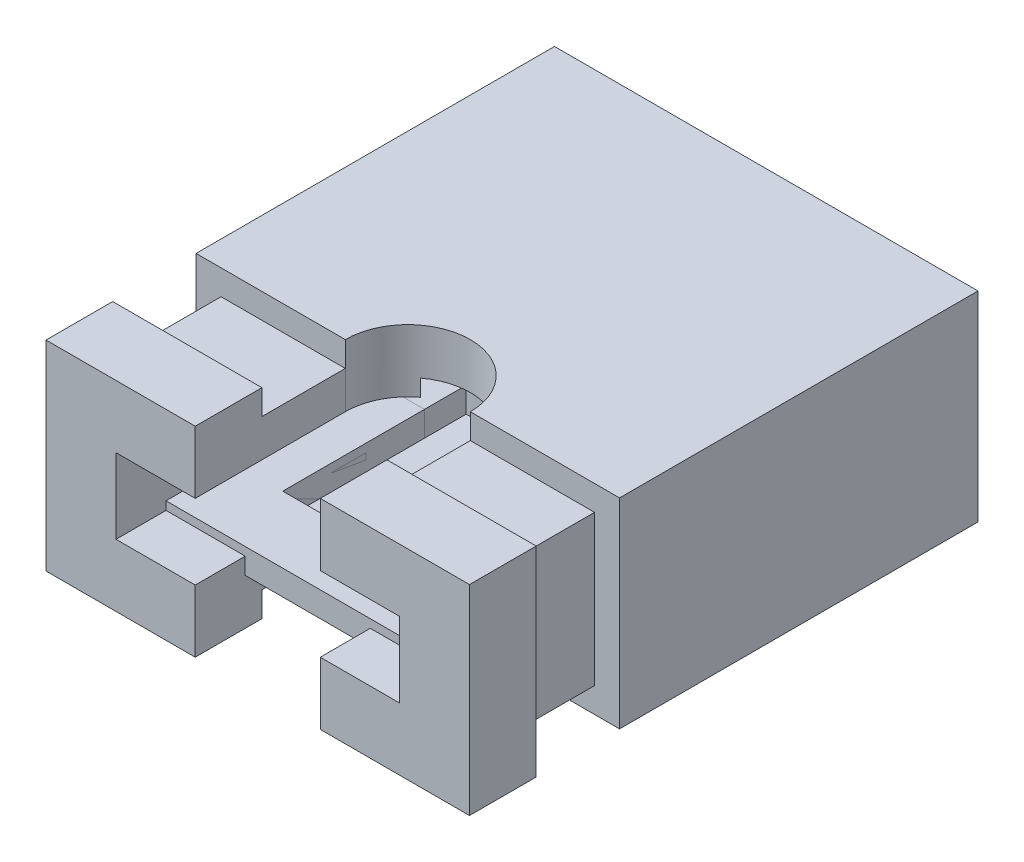
from build123d import *

# Parameters (mm, degrees)
SKETCH1_W           = 5.08
SKETCH1_H           = 2.4
SKETCH1_W_2         = 3.799999998
SKETCH1_H_2         = 1.299999999
BOSS_EXTRUDE1_DEPTH = 4.3
SKETCH3_R           = 0.75
CUT_EXTRUDE2_DEPTH  = 3.4
BOSS_EXTRUDE2_DEPTH = 1
BOSS_EXTRUDE3_DEPTH = 0.8
BOSS_EXTRUDE4_DEPTH = 2.4
CUT_EXTRUDE4_DEPTH  = 2.849999999
BOSS_EXTRUDE5_DEPTH = 3
BOSS_EXTRUDE8_DEPTH = 2.5
SKETCH14_W          = 2.199999998
SKETCH14_H          = 2.2
CUT_EXTRUDE5_DEPTH  = 0.3


with BuildPart() as part:
    # Sketch1 → Boss-Extrude1 (new body)
    with BuildSketch(Plane.XY):
        Rectangle(SKETCH1_W, SKETCH1_H)
        Rectangle(SKETCH1_W_2, SKETCH1_H_2, mode=Mode.SUBTRACT)
    extrude(amount=BOSS_EXTRUDE1_DEPTH)

    # Sketch3 → Cut-Extrude2 (cut, through all)
    with BuildSketch(Plane(origin=(0, 1.2, 0), x_dir=(1, 0, 0), z_dir=(0, 1, 0))):
        with Locations((0, -4.3)):
            Circle(SKETCH3_R)
    extrude(amount=-CUT_EXTRUDE2_DEPTH, mode=Mode.SUBTRACT)

    # Sketch6 → Boss-Extrude2 (add)
    with BuildSketch(Plane.XY.offset(4.3)):
        Polygon((-0.75, 0.9), (-0.75, 0.649999999), (-1.899999999, 0.649999999), (-1.899999999, -0.65), (-0.75, -0.65), (-0.75, -0.9), (-2.24, -0.9), (-2.24, 0.9), align=None)
        Polygon((2.24, 0.9), (2.24, -0.9), (0.75, -0.9), (0.75, -0.65), (1.899999999, -0.65), (1.899999999, 0.649999999), (0.75, 0.649999999), (0.75, 0.9), align=None)
    extrude(amount=BOSS_EXTRUDE2_DEPTH)

    # Sketch7 → Boss-Extrude3 (add)
    with BuildSketch(Plane.XY.offset(5.3)):
        Polygon((-0.75, 1.2), (-0.75, 0.9), (-0.75, 0.649999999), (-1.899999999, 0.649999999), (-1.899999999, -0.65), (-0.75, -0.65), (-0.75, -0.9), (-0.75, -1.2), (-2.54, -1.2), (-2.54, 1.2), align=None)
        Polygon((0.75, -0.9), (0.75, -1.2), (2.54, -1.2), (2.54, 1.2), (0.75, 1.2), (0.75, 0.9), (0.75, 0.649999999), (1.899999999, 0.649999999), (1.899999999, -0.65), (0.75, -0.65), align=None)
    extrude(amount=BOSS_EXTRUDE3_DEPTH)

    # Sketch9 → Boss-Extrude4 (add)
    with BuildSketch(Plane.XY.offset(6.1)):
        Polygon((0.75, 0.649999999), (1.899999999, 0.649999999), (1.899999999, -0.65), (0.75, -0.65), (-0.75, -0.65), (-1.899999999, -0.65), (-1.899999999, 0.649999999), (-0.75, 0.649999999), align=None)
        Polygon((-0.75, -0.45), (-1.699999999, -0.45), (-1.699999999, 0.449999999), (-0.75, 0.449999999), (0.75, 0.449999999), (1.699999999, 0.449999999), (1.699999999, -0.45), (0.75, -0.45), align=None, mode=Mode.SUBTRACT)
    extrude(amount=-BOSS_EXTRUDE4_DEPTH)

    # Sketch10 → Cut-Extrude4 (cut, through all)
    with BuildSketch(Plane(origin=(0, 0.649999999, 0), x_dir=(1, 0, 0), z_dir=(0, 1, 0))):
        with BuildLine():
            Line((0.75, -6.1), (0.75, -4.3))
            ThreePointArc((0.75, -4.3), (0.670820393, -3.964589803), (0.45, -3.7))
            ThreePointArc((0.45, -3.7), (0, -3.55), (-0.45, -3.7))
            ThreePointArc((-0.45, -3.7), (-0.670820393, -3.964589803), (-0.75, -4.3))
            Line((-0.75, -4.3), (-0.75, -6.1))
            Line((-0.75, -6.1), (0.75, -6.1))
        make_face()
    extrude(amount=-CUT_EXTRUDE4_DEPTH, mode=Mode.SUBTRACT)


with BuildPart() as body_2:
    # Sketch12 → Boss-Extrude5 (new body)
    with BuildSketch(Plane(origin=(0, 0, 0), x_dir=(-1, 0, 0), z_dir=(0, 0, -1))):
        Polygon((1.899999999, 0.649999999), (1.899999999, -0.65), (-1.899999999, -0.65), (-1.899999999, 0.649999999), (-1.599999999, 0.649999999), (-1.599999999, -0.35), (1.599999999, -0.35), (1.599999999, 0.649999999), align=None)
    extrude(amount=-BOSS_EXTRUDE5_DEPTH)


with BuildPart() as body_3:
    # Sketch13 → Boss-Extrude8 (new body)
    with BuildSketch(Plane.XY.offset(3)):
        Polygon((1.899999999, -0.65), (-1.899999999, -0.65), (-1.899999999, -0.35), (-1.599999999, -0.35), (1.599999999, -0.35), (1.899999999, -0.35), align=None)
    extrude(amount=BOSS_EXTRUDE8_DEPTH)


with BuildPart() as cut_extrude5_tool:
    # Sketch14 → Cut-Extrude5 (new body)
    with BuildSketch(Plane(origin=(0, -0.35, 0), x_dir=(1, 0, 0), z_dir=(0, 1, 0))):
        with Locations((0, -3.6)):
            Rectangle(SKETCH14_W, SKETCH14_H)
    extrude(amount=-CUT_EXTRUDE5_DEPTH)


with BuildPart() as part_1:
    add(part.part)

    # Cut-Extrude5: cut by cut_extrude5_tool
    add(cut_extrude5_tool.part, mode=Mode.SUBTRACT)


with BuildPart() as body_2_1:
    add(body_2.part)

    # Cut-Extrude5: cut by cut_extrude5_tool
    add(cut_extrude5_tool.part, mode=Mode.SUBTRACT)


with BuildPart() as body_3_1:
    add(body_3.part)

    # Cut-Extrude5: cut by cut_extrude5_tool
    add(cut_extrude5_tool.part, mode=Mode.SUBTRACT)


solid = Compound([part_1.part, body_2_1.part, body_3_1.part])
